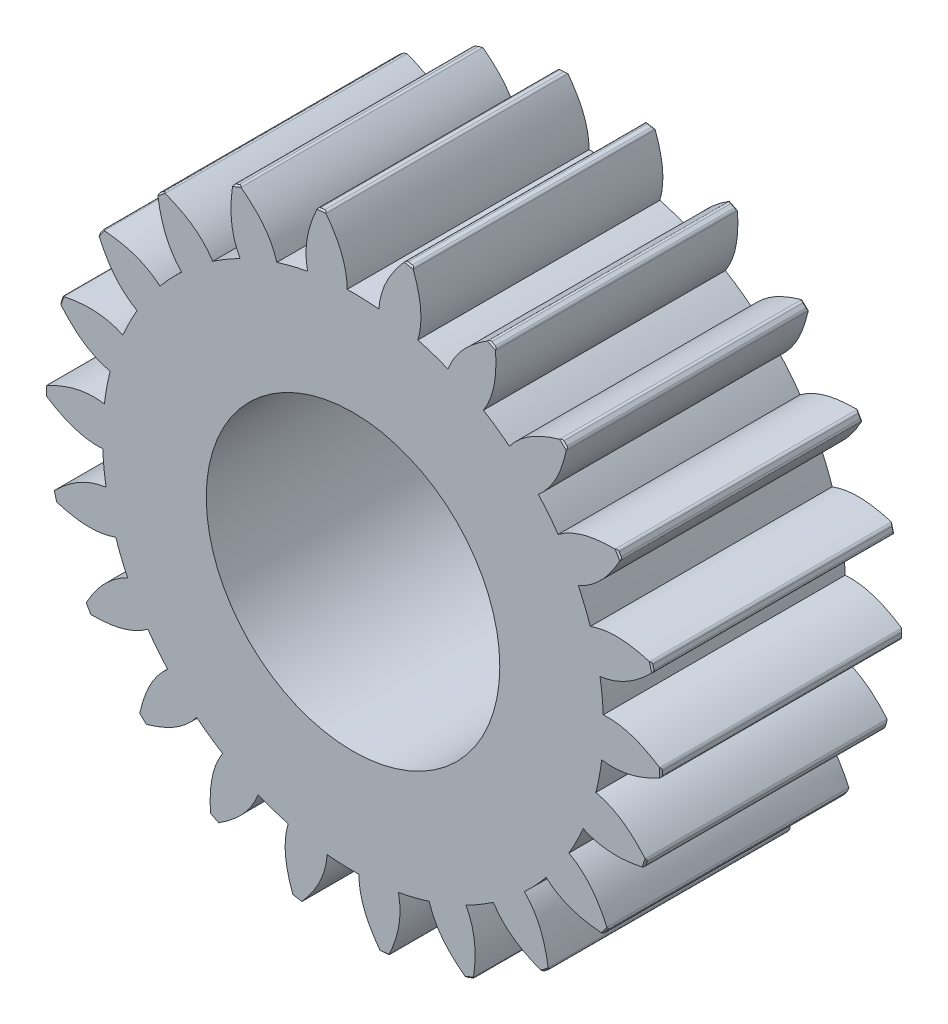
from build123d import *

# Parameters (mm, degrees)
BOSS_EXTRUDE2_DEPTH           = 32.97
CHAMFER2_SIZE                 = 0.2
CHAMFER3_SIZE                 = 0.2
FILLET3_R                     = 0.4
CIRPATTERN20_COUNT            = 22
CHAMFER2_OF_CIRPATTERN20_SIZE = 0.2
CHAMFER3_OF_CIRPATTERN20_SIZE = 0.2
FILLET3_OF_CIRPATTERN20_R     = 0.4
SKETCH2_R                     = 20
CUT_EXTRUDE1_DEPTH            = 33.9700001


with BuildPart() as part:
    # Sketch1 → Boss-Extrude2 (new body)
    with BuildSketch(Plane.XY):
        with BuildLine():
            add(Edge.make_bspline(
                [(-0.804315567, 34.11551995), (-0.795422826, 35.299077988), (-1.323288202, 38.066705897), (-2.803604898, 40.49742117), (-3.812211049, 41.826630834)],
                knots=[-0.063749931, -0.063749931, -0.063749931, -0.063749931, 0.062665735, 0.246997893, 0.246997893, 0.246997893, 0.246997893], degree=3))
            ThreePointArc((-3.812211049, 41.826630834), (-4.318301153, 41.777413457), (-4.823758323, 41.722072763))
            add(Edge.make_bspline(
                [(-4.823758323, 41.722072763), (-5.539158883, 40.214661596), (-6.490990325, 37.532549195), (-6.441594839, 34.715464248), (-6.19080089, 33.558748626)],
                knots=[0, 0, 0, 0, 0.184332159, 0.310747825, 0.310747825, 0.310747825, 0.310747825], degree=3))
            ThreePointArc((-6.19080089, 33.558748626), (3.508619691, -33.944148433), (-0.804315567, 34.11551995))
        make_face()
    boss_extrude2 = extrude(amount=BOSS_EXTRUDE2_DEPTH)

    # Chamfer2
    chamfer2_edges = [part.edges().sort_by_distance(p)[0] for p in [
        (-4.318301153, 41.777413457, 32.97),
    ]]
    chamfer(chamfer2_edges, length=CHAMFER2_SIZE)

    # Chamfer3
    chamfer3_edges = [part.edges().sort_by_distance(p)[0] for p in [
        (-4.318301153, 41.777413457, 0),
    ]]
    chamfer(chamfer3_edges, length=CHAMFER3_SIZE)

    # Fillet3
    fillet3_edges = [part.edges().sort_by_distance(p)[0] for p in [
        (-4.823758323, 41.722072763, 16.485),
        (-3.812211049, 41.826630834, 16.485),
    ]]
    fillet(fillet3_edges, radius=FILLET3_R)

    # CirPattern20: Boss-Extrude2 ×22 about axis
    cirpattern20_axis = Axis((0, 0, 32.97), (0, 0, 1))
    for i in range(1, CIRPATTERN20_COUNT):
        add(boss_extrude2.rotate(cirpattern20_axis, i * 360 / CIRPATTERN20_COUNT))

    # Chamfer2 of CirPattern20
    chamfer2_of_cirpattern20_edges = [part.edges().sort_by_distance(p)[0] for p in [
        (-15.913437125, 38.868528643, 32.97),
        (-26.219361063, 32.810746798, 32.97),
        (-34.4011483, 24.094833381, 32.97),
        (-39.795959093, 13.42689986, 32.97),
        (-41.966737956, 1.671198766, 32.97),
        (-40.737621296, -10.219892913, 32.97),
        (-36.208184834, -21.283029648, 32.97),
        (-28.745376576, -30.621941897, 32.97),
        (-18.953788862, -37.480046528, 32.97),
        (-7.626677898, -41.301740693, 32.97),
        (4.318301153, -41.777413457, 32.97),
        (15.913437125, -38.868528643, 32.97),
        (26.219361063, -32.810746798, 32.97),
        (34.4011483, -24.094833381, 32.97),
        (39.795959093, -13.42689986, 32.97),
        (41.966737956, -1.671198766, 32.97),
        (40.737621296, 10.219892913, 32.97),
        (36.208184834, 21.283029648, 32.97),
        (28.745376576, 30.621941897, 32.97),
        (18.953788862, 37.480046528, 32.97),
        (7.626677898, 41.301740693, 32.97),
    ]]
    chamfer(chamfer2_of_cirpattern20_edges, length=CHAMFER2_OF_CIRPATTERN20_SIZE)

    # Chamfer3 of CirPattern20
    chamfer3_of_cirpattern20_edges = [part.edges().sort_by_distance(p)[0] for p in [
        (-15.913437125, 38.868528643, 0),
        (-26.219361063, 32.810746798, 0),
        (-34.4011483, 24.094833381, 0),
        (-39.795959093, 13.42689986, 0),
        (-41.966737956, 1.671198766, 0),
        (-40.737621296, -10.219892913, 0),
        (-36.208184834, -21.283029648, 0),
        (-28.745376576, -30.621941897, 0),
        (-18.953788862, -37.480046528, 0),
        (-7.626677898, -41.301740693, 0),
        (4.318301153, -41.777413457, 0),
        (15.913437125, -38.868528643, 0),
        (26.219361063, -32.810746798, 0),
        (34.4011483, -24.094833381, 0),
        (39.795959093, -13.42689986, 0),
        (41.966737956, -1.671198766, 0),
        (40.737621296, 10.219892913, 0),
        (36.208184834, 21.283029648, 0),
        (28.745376576, 30.621941897, 0),
        (18.953788862, 37.480046528, 0),
        (7.626677898, 41.301740693, 0),
    ]]
    chamfer(chamfer3_of_cirpattern20_edges, length=CHAMFER3_OF_CIRPATTERN20_SIZE)

    # Fillet3 of CirPattern20
    fillet3_of_cirpattern20_edges = [part.edges().sort_by_distance(p)[0] for p in [
        (-16.382828453, 38.673025895, 16.485),
        (-15.441713364, 39.058334429, 16.485),
        (-26.614659255, 32.490920466, 16.485),
        (-25.820219898, 33.125764058, 16.485),
        (-34.690328647, 23.676593892, 16.485),
        (-34.106925775, 24.509541289, 16.485),
        (-39.955593924, 12.944130491, 16.485),
        (-39.630491367, 13.907701248, 16.485),
        (-41.983894606, 1.16301062, 16.485),
        (-41.94343024, 2.179141965, 16.485),
        (-40.610909835, -10.712329456, 16.485),
        (-40.858361842, -9.72595844, 16.485),
        (-35.947870671, -21.719820307, 16.485),
        (-36.463191962, -20.843119535, 16.485),
        (-28.372548816, -30.96770049, 16.485),
        (-29.113991124, -30.271695044, 16.485),
        (-18.498651794, -37.706761752, 16.485),
        (-19.406147873, -37.247837853, 16.485),
        (-7.126104019, -41.391045427, 16.485),
        (-8.126133933, -41.206382361, 16.485),
        (4.823758323, -41.722072763, 16.485),
        (3.812211049, -41.826630834, 16.485),
        (16.382828453, -38.673025895, 16.485),
        (15.441713364, -39.058334429, 16.485),
        (26.614659255, -32.490920466, 16.485),
        (25.820219898, -33.125764058, 16.485),
        (34.690328647, -23.676593892, 16.485),
        (34.106925775, -24.509541289, 16.485),
        (39.955593924, -12.944130491, 16.485),
        (39.630491367, -13.907701248, 16.485),
        (41.983894606, -1.16301062, 16.485),
        (41.94343024, -2.179141965, 16.485),
        (40.610909835, 10.712329456, 16.485),
        (40.858361842, 9.72595844, 16.485),
        (35.947870671, 21.719820307, 16.485),
        (36.463191962, 20.843119535, 16.485),
        (28.372548816, 30.96770049, 16.485),
        (29.113991124, 30.271695044, 16.485),
        (18.498651794, 37.706761752, 16.485),
        (19.406147873, 37.247837853, 16.485),
        (7.126104019, 41.391045427, 16.485),
        (8.126133933, 41.206382361, 16.485),
    ]]
    fillet(fillet3_of_cirpattern20_edges, radius=FILLET3_OF_CIRPATTERN20_R)

    # Sketch2 → Cut-Extrude1 (cut, through all)
    with BuildSketch(Plane.XY.offset(32.97)):
        Circle(SKETCH2_R)
    extrude(amount=-CUT_EXTRUDE1_DEPTH, mode=Mode.SUBTRACT)


solid = part.part
